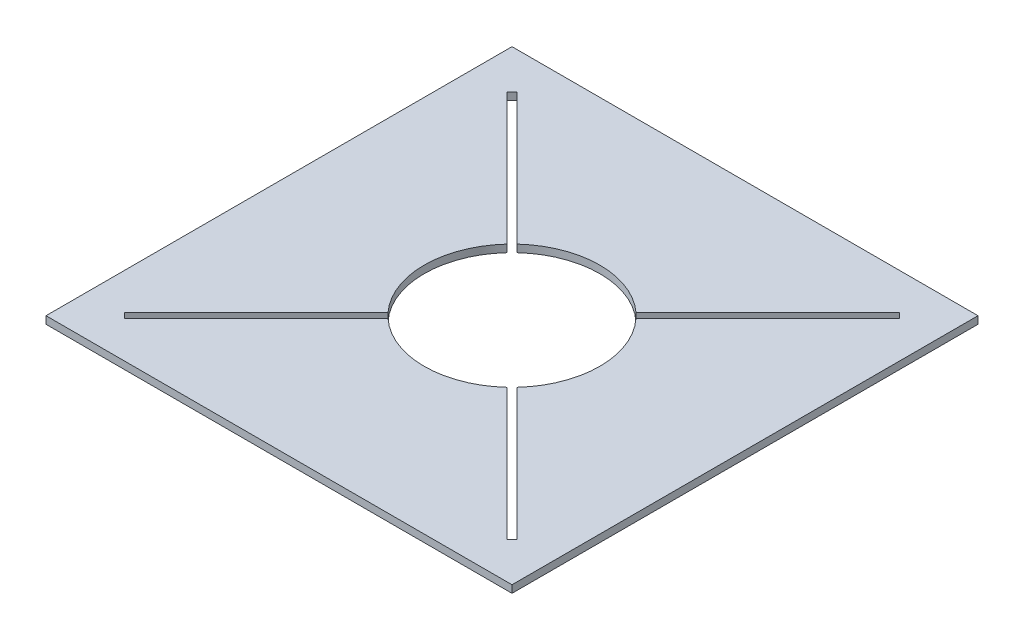
from build123d import *

# Parameters (mm, degrees)
SKETCH4_W           = 413.09178157
SKETCH4_H           = 413.09178157
BOSS_EXTRUDE3_DEPTH = 6.604
SKETCH6_R           = 77.79258
CUT_EXTRUDE1_DEPTH  = 6.604
CUT_EXTRUDE2_DEPTH  = 6.604
CUT_EXTRUDE3_DEPTH  = 6.604


with BuildPart() as part:
    # Sketch4 → Boss-Extrude3 (new body)
    with BuildSketch(Plane(origin=(0, 0, 0), x_dir=(1, 0, 0), z_dir=(0, 1, 0))):
        Rectangle(SKETCH4_W, SKETCH4_H)
    extrude(amount=BOSS_EXTRUDE3_DEPTH)

    # Sketch6 → Cut-Extrude1 (cut)
    with BuildSketch(Plane(origin=(0, 6.604, 0), x_dir=(1, 0, 0), z_dir=(0, 1, 0))):
        Circle(SKETCH6_R)
    extrude(amount=-CUT_EXTRUDE1_DEPTH, mode=Mode.SUBTRACT)

    # Sketch8 → Cut-Extrude2 (cut)
    with BuildSketch(Plane(origin=(0, 6.604, 0), x_dir=(1, 0, 0), z_dir=(0, 1, 0))):
        Polygon((-174.055324139, -169.457433005), (169.457433005, 174.055324139), (174.055324139, 169.457433005), (-169.457433005, -174.055324139), align=None)
    extrude(amount=-CUT_EXTRUDE2_DEPTH, mode=Mode.SUBTRACT)

    # Sketch9 → Cut-Extrude3 (cut)
    with BuildSketch(Plane(origin=(0, 6.604, 0), x_dir=(1, 0, 0), z_dir=(0, 1, 0))):
        Polygon((174.064304395, -169.448452748), (-169.448452748, 174.064304395), (-174.064304395, 169.448452748), (169.448452748, -174.064304395), align=None)
    extrude(amount=-CUT_EXTRUDE3_DEPTH, mode=Mode.SUBTRACT)


solid = part.part
